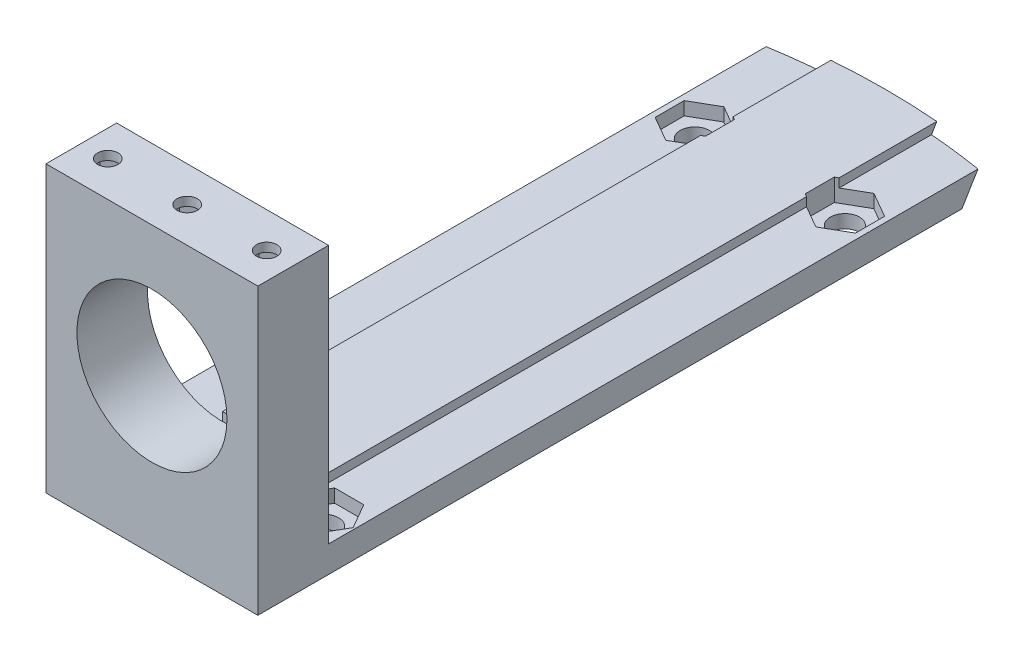
from build123d import *

# Parameters (mm, degrees)
SKETCH1_W               = 24
SKETCH1_H               = 81.502166862
BOSS_EXTRUDE1_DEPTH     = 3
SKETCH2_R               = 1.65
CUT_EXTRUDE1_DEPTH      = 4
BOSS_EXTRUDE2_START     = -6
SKETCH3_W               = 12
SKETCH3_H               = 1
BOSS_EXTRUDE2_DEPTH     = 75.502167
CUT_EXTRUDE2_DEPTH      = 2
CUT_EXTRUDE2_DEPTH_BACK = 1.5
SKETCH6_W               = 24
SKETCH6_H               = 32.3
SKETCH6_R               = 8.5
BOSS_EXTRUDE3_DEPTH     = 8
SKETCH9_R               = 1.15
CUT_EXTRUDE3_DEPTH      = 5
CUT_EXTRUDE4_START      = -1
CUT_EXTRUDE4_DEPTH      = 1.8


with BuildPart() as part:
    # Sketch1 → Boss-Extrude1 (new body)
    with BuildSketch(Plane(origin=(0, 0, 0), x_dir=(1, 0, 0), z_dir=(0, 1, 0))):
        with Locations((12, 40.751083431)):
            Rectangle(SKETCH1_W, SKETCH1_H)
    extrude(amount=BOSS_EXTRUDE1_DEPTH)

    # Sketch2 → Cut-Extrude1 (cut, through all)
    with BuildSketch(Plane(origin=(0, 0, 0), x_dir=(1, 0, 0), z_dir=(0, 1, 0))):
        with Locations((3.5, 3)):
            Circle(SKETCH2_R)
        with Locations((12, 3)):
            Circle(SKETCH2_R)
        with Locations((20.5, 3)):
            Circle(SKETCH2_R)
        with Locations((3.5, 62)):
            Circle(SKETCH2_R)
        with Locations((20.5, 62)):
            Circle(SKETCH2_R)
    extrude(amount=CUT_EXTRUDE1_DEPTH, mode=Mode.SUBTRACT)

    # Sketch3 → Boss-Extrude2 (add)
    with BuildSketch(Plane.XY.offset(BOSS_EXTRUDE2_START)):
        with Locations((12, 3.5)):
            Rectangle(SKETCH3_W, SKETCH3_H)
    extrude(amount=-BOSS_EXTRUDE2_DEPTH)

    # Sketch4 → Cut-Revolve1 (revolve, cut)
    with BuildSketch(Plane(origin=(12, 0, 0), x_dir=(0, 0, -1), z_dir=(1, 0, 0))):
        Polygon((94.496458379, 36.241477716), (19.413701779, -88.89644995), (139.590265278, -88.89644995), (139.590265278, 36.241477716), align=None)
    revolve(axis=Axis((12, 0, 0), (0, 1, 0)), mode=Mode.SUBTRACT)

    # Sketch5 → Cut-Extrude2 (cut, two sides)
    with BuildSketch(Plane(origin=(0, 3, 0), x_dir=(1, 0, 0), z_dir=(0, 1, 0))) as cut_extrude2_sk:
        Polygon((15.290896534, 3), (13.645448267, 5.85), (10.354551733, 5.85), (8.709103466, 3), (10.354551733, 0.15), (13.645448267, 0.15), align=None)
        Polygon((23.790896534, 3), (22.145448267, 5.85), (18.854551733, 5.85), (17.209103466, 3), (18.854551733, 0.15), (22.145448267, 0.15), align=None)
        Polygon((6.790896534, 3), (5.145448267, 5.85), (1.854551733, 5.85), (0.209103466, 3), (1.854551733, 0.15), (5.145448267, 0.15), align=None)
        Polygon((6.35, 63.645448267), (3.5, 65.290896534), (0.65, 63.645448267), (0.65, 60.354551733), (3.5, 58.709103466), (6.35, 60.354551733), align=None)
        Polygon((23.35, 63.645448267), (20.5, 65.290896534), (17.65, 63.645448267), (17.65, 60.354551733), (20.5, 58.709103466), (23.35, 60.354551733), align=None)
    extrude(amount=CUT_EXTRUDE2_DEPTH, mode=Mode.SUBTRACT)
    extrude(cut_extrude2_sk.sketch, amount=-CUT_EXTRUDE2_DEPTH_BACK, mode=Mode.SUBTRACT)

    # Sketch6 → Boss-Extrude3 (add)
    with BuildSketch(Plane.XY):
        with Locations((12, 16.15)):
            Rectangle(SKETCH6_W, SKETCH6_H)
        with Locations((12, 17.5)):
            Circle(SKETCH6_R, mode=Mode.SUBTRACT)
    extrude(amount=BOSS_EXTRUDE3_DEPTH)

    # Sketch9 → Cut-Extrude3 (cut)
    with BuildSketch(Plane(origin=(0, 32.3, 0), x_dir=(1, 0, 0), z_dir=(0, 1, 0))):
        with Locations((3, -4)):
            Circle(SKETCH9_R)
        with Locations((12, -4)):
            Circle(SKETCH9_R)
        with Locations((21, -4)):
            Circle(SKETCH9_R)
    extrude(amount=-CUT_EXTRUDE3_DEPTH, mode=Mode.SUBTRACT)

    # Sketch10 → Cut-Extrude4 (cut)
    with BuildSketch(Plane(origin=(0, 32.3, 0), x_dir=(1, 0, 0), z_dir=(0, 1, 0)).offset(CUT_EXTRUDE4_START)):
        Polygon((3, -6.424871131), (5.1, -5.212435565), (5.1, -2.787564435), (3, -1.575128869), (0.9, -2.787564435), (0.9, -5.212435565), align=None)
        Polygon((12, -6.424871131), (14.1, -5.212435565), (14.1, -2.787564435), (12, -1.575128869), (9.9, -2.787564435), (9.9, -5.212435565), align=None)
        Polygon((21, -6.424871131), (23.1, -5.212435565), (23.1, -2.787564435), (21, -1.575128869), (18.9, -2.787564435), (18.9, -5.212435565), align=None)
    extrude(amount=-CUT_EXTRUDE4_DEPTH, mode=Mode.SUBTRACT)


solid = part.part
